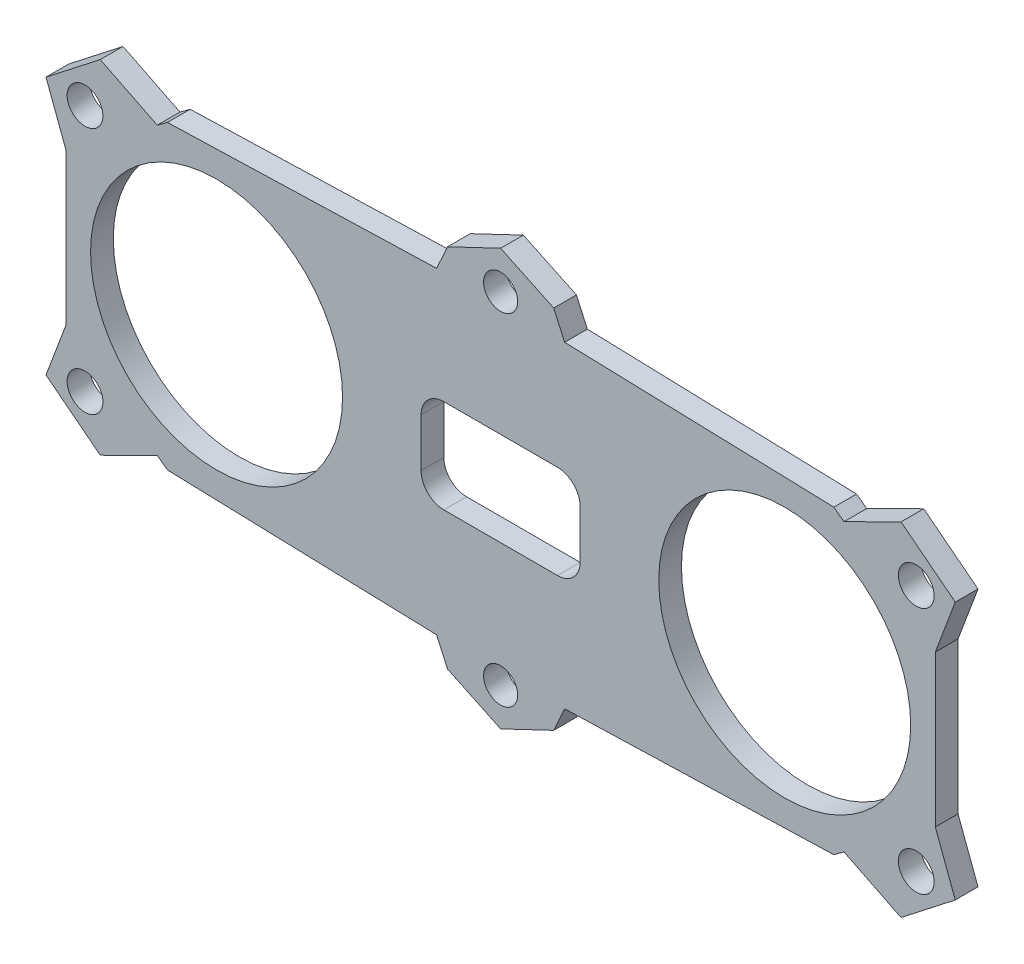
from build123d import *

# Parameters (mm, degrees)
SKETCH1_R           = 3
SKETCH1_R_2         = 22.175
BOSS_EXTRUDE1_DEPTH = 4
CUT_EXTRUDE1_DEPTH  = 5
SKETCH3_R           = 3.15
BOSS_EXTRUDE2_DEPTH = 4


with BuildPart() as part:
    # Sketch1 → Boss-Extrude1 (new body)
    with BuildSketch(Plane.XY):
        Polygon((0, 36.632796194), (-9.339584462, 32.184793438), (-11.263738257, 27.930920523), (-58.646229282, 26.490266956), (-76.5, 13.335918569), (-76.5, -13.335918569), (-58.646229282, -26.490266956), (-11.263738257, -27.930920523), (-9.339584462, -32.184793438), (0, -36.632796194), (9.339584462, -32.184793438), (11.263738257, -27.930920523), (58.646229282, -26.490266956), (76.5, -13.335918569), (76.5, 13.335918569), (58.646229282, 26.490266956), (11.263738257, 27.930920523), (9.339584462, 32.184793438), align=None)
        with Locations((0, 30)):
            Circle(SKETCH1_R, mode=Mode.SUBTRACT)
        with Locations((-50, 0)):
            Circle(SKETCH1_R_2, mode=Mode.SUBTRACT)
        with Locations((50, 0)):
            Circle(SKETCH1_R_2, mode=Mode.SUBTRACT)
        with Locations((0, -30)):
            Circle(SKETCH1_R, mode=Mode.SUBTRACT)
    extrude(amount=BOSS_EXTRUDE1_DEPTH)

    # Sketch2 → Cut-Extrude1 (cut, through all)
    with BuildSketch(Plane.XY.offset(4)):
        with BuildLine():
            Line((10, 8.25), (-10, 8.25))
            ThreePointArc((-10, 8.25), (-12.828427125, 7.078427125), (-14, 4.25))
            Line((-14, 4.25), (-14, -4.25))
            ThreePointArc((-14, -4.25), (-12.828427125, -7.078427125), (-10, -8.25))
            Line((-10, -8.25), (10, -8.25))
            ThreePointArc((10, -8.25), (12.828427125, -7.078427125), (14, -4.25))
            Line((14, -4.25), (14, 4.25))
            ThreePointArc((14, 4.25), (12.828427125, 7.078427125), (10, 8.25))
        make_face()
    extrude(amount=-CUT_EXTRUDE1_DEPTH, mode=Mode.SUBTRACT)

    # Sketch3 → Boss-Extrude2 (add)
    with BuildSketch(Plane.XY.offset(4)):
        Polygon((-60.436095429, 25.171524645), (-70.470429489, 30.155905977), (-80.018831674, 22.70201384), (-76.5, 13.335918569), align=None)
        with Locations((-73.15, 21.8)):
            Circle(SKETCH3_R, mode=Mode.SUBTRACT)
        Polygon((76.5, 13.335918569), (60.436095429, 25.171524645), (70.470429489, 30.155905977), (80.018831674, 22.70201384), align=None)
        with Locations((73.15, 21.8)):
            Circle(SKETCH3_R, mode=Mode.SUBTRACT)
        Polygon((60.436095429, -25.171524645), (70.470429489, -30.155905977), (80.018831674, -22.70201384), (76.5, -13.335918569), align=None)
        with Locations((73.15, -21.8)):
            Circle(SKETCH3_R, mode=Mode.SUBTRACT)
        Polygon((-76.5, -13.335918569), (-60.436095429, -25.171524645), (-70.470429489, -30.155905977), (-80.018831674, -22.70201384), align=None)
        with Locations((-73.15, -21.8)):
            Circle(SKETCH3_R, mode=Mode.SUBTRACT)
    extrude(amount=-BOSS_EXTRUDE2_DEPTH)


solid = part.part
